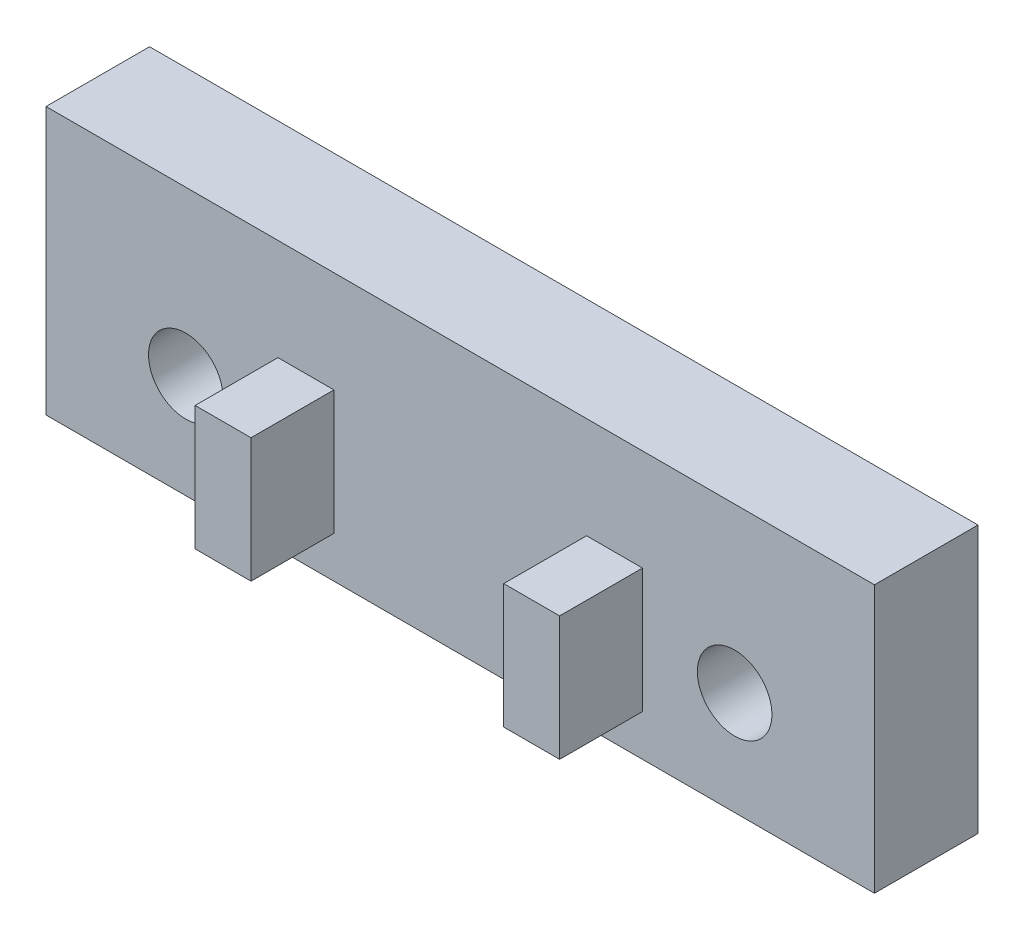
from build123d import *

# Parameters (mm, degrees)
SKETCH1_W            = 40
SKETCH1_H            = 10
BOSS_EXTRUDE1_DEPTH  = 5
M3_CLEARANCE_HOLE1_D = 3.6
SKETCH4_W            = 2.7
SKETCH4_H            = 6
BOSS_EXTRUDE2_DEPTH  = 4
SKETCH5_W            = 40
SKETCH5_H            = 5
BOSS_EXTRUDE3_DEPTH  = 2.9


with BuildPart() as part:
    # Sketch1 → Boss-Extrude1 (new body)
    with BuildSketch(Plane.XY):
        Rectangle(SKETCH1_W, SKETCH1_H)
    extrude(amount=BOSS_EXTRUDE1_DEPTH)

    # M3 Clearance Hole1 (through all)
    with Locations(Plane(origin=(0, 0, 0), x_dir=(1, 0, 0), z_dir=(0, 0, -1))):
        with Locations((-13.25, 0), (13.25, 0)):
            Hole(M3_CLEARANCE_HOLE1_D / 2)

    # Sketch4 → Boss-Extrude2 (add)
    with BuildSketch(Plane.XY.offset(5)):
        with Locations((-7.45, 0)):
            Rectangle(SKETCH4_W, SKETCH4_H)
        with Locations((7.45, 0)):
            Rectangle(SKETCH4_W, SKETCH4_H)
    extrude(amount=BOSS_EXTRUDE2_DEPTH)

    # Sketch5 → Boss-Extrude3 (add)
    with BuildSketch(Plane(origin=(0, 5, 0), x_dir=(1, 0, 0), z_dir=(0, 1, 0))):
        with Locations((0, -2.5)):
            Rectangle(SKETCH5_W, SKETCH5_H)
    extrude(amount=BOSS_EXTRUDE3_DEPTH)


solid = part.part
